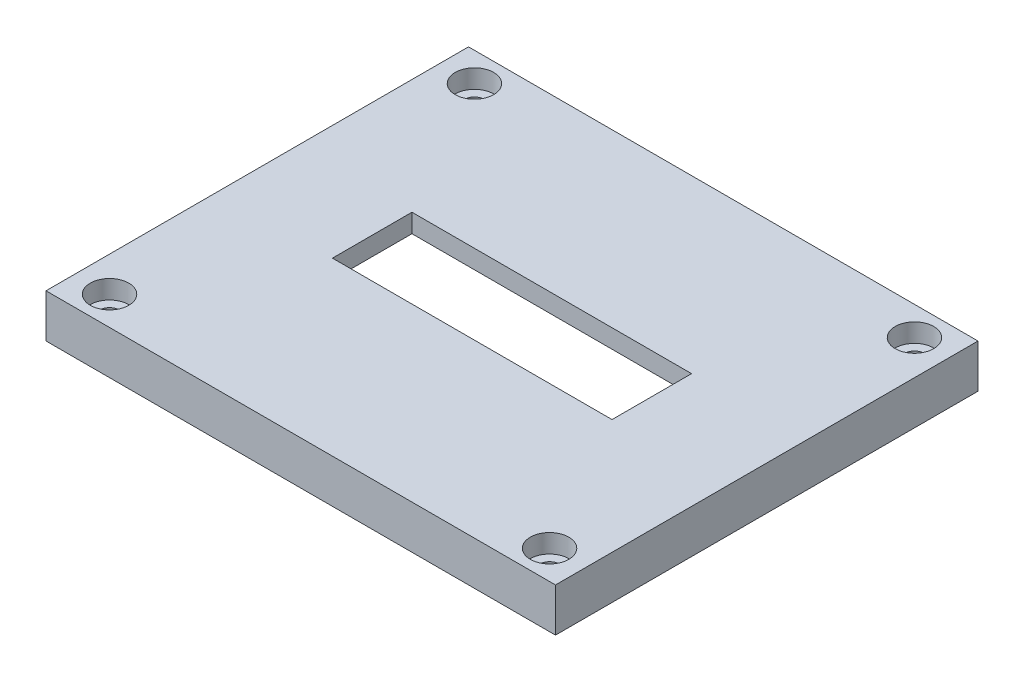
from build123d import *

# Parameters (mm, degrees)
SKETCH1_W             = 76
SKETCH1_H             = 62
BOSS_EXTRUDE1_DEPTH   = 2
SKETCH2_W             = 82
SKETCH2_H             = 68
BOSS_EXTRUDE2_DEPTH   = 8
SKETCH3_W             = 45
SKETCH3_H             = 12.8
CUT_EXTRUDE1_DEPTH    = 11
SKETCH4_R             = 1.6
CUT_EXTRUDE2_DEPTH    = 11
SKETCH5_R             = 3.1
CUT_EXTRUDE3_DEPTH    = 3
SKETCH9_OUTSIDE_W     = 105.4
SKETCH9_OUTSIDE_H     = 91.4
SKETCH9_OUTSIDE_W_2   = 75.6
SKETCH9_OUTSIDE_H_2   = 61.6
CUT_EXTRUDE5_DEPTH    = 3
CUT_EXTRUDE6_DEPTH    = 3
SKETCH11_W            = 66
SKETCH11_H            = 54
CUT_EXTRUDE7_DEPTH    = 7
CHAMFER2_SIZE         = 2
CHAMFER2_SIZE2        = 0.352653961
CHAMFER2_PART_2_SIZE  = 2
CHAMFER2_PART_2_SIZE2 = 0.352653961
CHAMFER3_SIZE         = 1
CHAMFER3_SIZE2        = 1.732050808


with BuildPart() as part:
    # Sketch1 → Boss-Extrude1 (new body)
    with BuildSketch(Plane(origin=(0, 0, 0), x_dir=(1, 0, 0), z_dir=(0, 1, 0))):
        Rectangle(SKETCH1_W, SKETCH1_H)
    extrude(amount=BOSS_EXTRUDE1_DEPTH)

    # Sketch2 → Boss-Extrude2 (add)
    with BuildSketch(Plane(origin=(0, 2, 0), x_dir=(1, 0, 0), z_dir=(0, 1, 0))):
        Rectangle(SKETCH2_W, SKETCH2_H)
    extrude(amount=BOSS_EXTRUDE2_DEPTH)

    # Sketch3 → Cut-Extrude1 (cut, through all)
    with BuildSketch(Plane.XZ):
        Rectangle(SKETCH3_W, SKETCH3_H)
    extrude(amount=-CUT_EXTRUDE1_DEPTH, mode=Mode.SUBTRACT)

    # Sketch4 → Cut-Extrude2 (cut, through all)
    with BuildSketch(Plane(origin=(0, 10, 0), x_dir=(1, 0, 0), z_dir=(0, 1, 0))):
        with Locations(Location((-35.408866178, 29.363450001, 0), (0, 0, 270))):  # turned: the seam where the file's is
            Circle(SKETCH4_R)
        with Locations(Location((35.408866178, 29.363450001, 0), (0, 0, 270))):  # turned: the seam where the file's is
            Circle(SKETCH4_R)
        with Locations(Location((35.408866178, -29.363450001, 0), (0, 0, 270))):  # turned: the seam where the file's is
            Circle(SKETCH4_R)
        with Locations(Location((-35.408866178, -29.363450001, 0), (0, 0, 270))):  # turned: the seam where the file's is
            Circle(SKETCH4_R)
    extrude(amount=-CUT_EXTRUDE2_DEPTH, mode=Mode.SUBTRACT)

    # Sketch5 → Cut-Extrude3 (cut)
    with BuildSketch(Plane(origin=(0, 10, 0), x_dir=(1, 0, 0), z_dir=(0, 1, 0))):
        with Locations(Location((-35.408866178, 29.363450001, 0), (0, 0, 270))):  # turned: the seam where the file's is
            Circle(SKETCH5_R)
        with Locations(Location((35.408866178, 29.363450001, 0), (0, 0, 270))):  # turned: the seam where the file's is
            Circle(SKETCH5_R)
        with Locations(Location((35.408866178, -29.363450001, 0), (0, 0, 270))):  # turned: the seam where the file's is
            Circle(SKETCH5_R)
        with Locations(Location((-35.408866178, -29.363450001, 0), (0, 0, 270))):  # turned: the seam where the file's is
            Circle(SKETCH5_R)
    extrude(amount=-CUT_EXTRUDE3_DEPTH, mode=Mode.SUBTRACT)

    # Sketch9 outside → Cut-Extrude5 (cut)
    with BuildSketch(Plane.XZ):
        Rectangle(SKETCH9_OUTSIDE_W, SKETCH9_OUTSIDE_H)
        Rectangle(SKETCH9_OUTSIDE_W_2, SKETCH9_OUTSIDE_H_2, mode=Mode.SUBTRACT)
    extrude(amount=-CUT_EXTRUDE5_DEPTH, mode=Mode.SUBTRACT)

    # Sketch10 → Cut-Extrude6 (cut)
    with BuildSketch(Plane.XZ):
        Polygon((-37.8, -30.8), (-31.8, -30.8), (-37.8, -24.8), align=None)
        Polygon((-37.8, 24.8), (-37.8, 30.8), (-31.8, 30.8), align=None)
        Polygon((37.8, 30.8), (37.8, 24.8), (31.8, 30.8), align=None)
        Polygon((37.8, -30.8), (31.8, -30.8), (37.8, -24.8), align=None)
    extrude(amount=-CUT_EXTRUDE6_DEPTH, mode=Mode.SUBTRACT)

    # Sketch11 → Cut-Extrude7 (cut)
    with BuildSketch(Plane.XZ):
        Rectangle(SKETCH11_W, SKETCH11_H)
    extrude(amount=-CUT_EXTRUDE7_DEPTH, mode=Mode.SUBTRACT)

    # Chamfer2
    chamfer2_edges = [part.edges().sort_by_distance(p)[0] for p in [
        (37.8, 0, 0),
    ]]
    chamfer2_side = [part.faces().sort_by_distance(p)[0] for p in [
        (37.8, 1.5, 0),
    ]]
    chamfer(chamfer2_edges, length=CHAMFER2_SIZE, length2=CHAMFER2_SIZE2, reference=chamfer2_side[0])

    # Chamfer2 part 2
    chamfer2_part_2_edges = [part.edges().sort_by_distance(p)[0] for p in [
        (-37.8, 0, 0),
    ]]
    chamfer2_part_2_side = [part.faces().sort_by_distance(p)[0] for p in [
        (-37.8, 1.5, 0),
    ]]
    chamfer(chamfer2_part_2_edges, length=CHAMFER2_PART_2_SIZE, length2=CHAMFER2_PART_2_SIZE2, reference=chamfer2_part_2_side[0])

    # Chamfer3
    chamfer3_edges = [part.edges().sort_by_distance(p)[0] for p in [
        (0, 0, -30.8),
        (0, 0, 30.8),
    ]]
    chamfer3_side = [part.faces().sort_by_distance(p)[0] for p in [
        (-35.357643735, 0, 25.870950059),
    ]]
    chamfer(chamfer3_edges, length=CHAMFER3_SIZE, length2=CHAMFER3_SIZE2, reference=chamfer3_side[0])


solid = part.part
